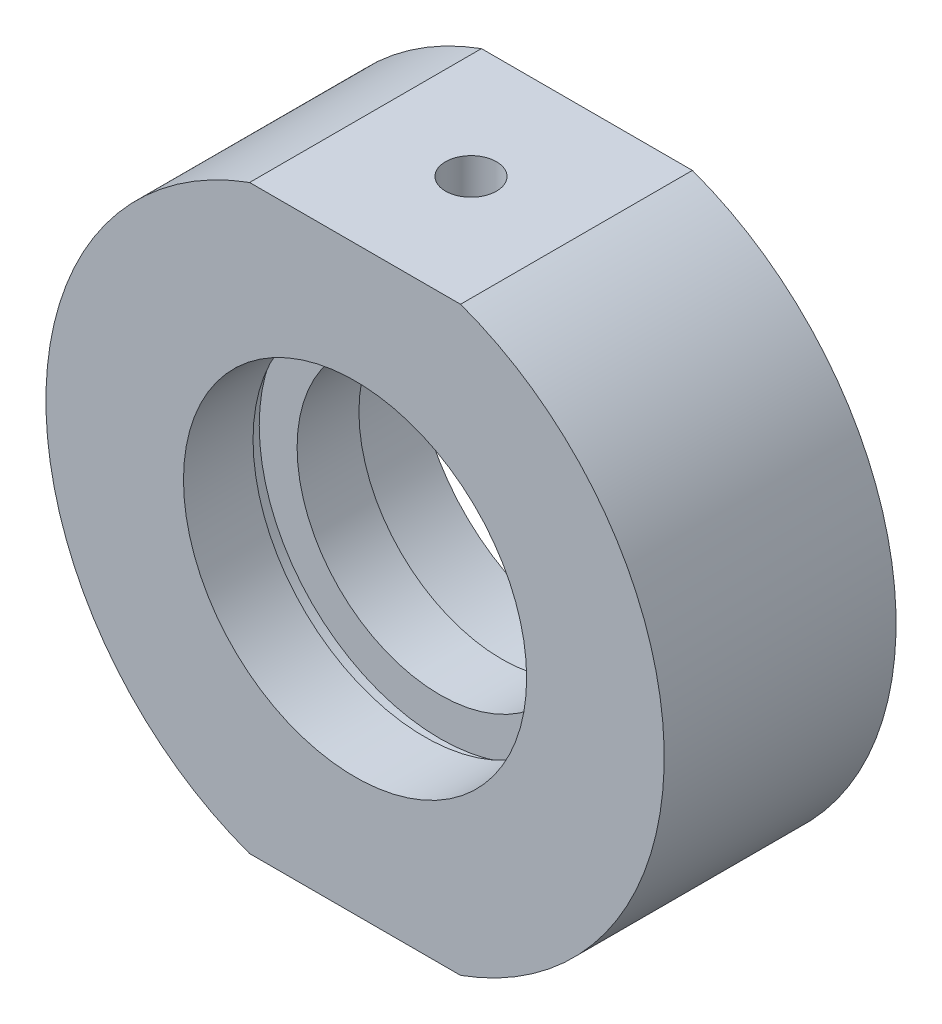
from build123d import *

# Parameters (mm, degrees)
SKETCH_2_W             = 64.02174429
SKETCH_2_H             = 9.248919907
CUT_EXTRUDE_1_DEPTH    = 49
HOLE_WIZARD_M4_2_D     = 3.3
HOLE_WIZARD_M4_2_DEPTH = 5.5
HOLE_WIZARD_M4_2_TIP   = 0.991420021
HOLE_WIZARD_M6_2_D     = 5
HOLE_WIZARD_M6_2_DEPTH = 5.5
HOLE_WIZARD_M6_2_TIP   = 1.502151548


with BuildPart() as part:
    # 草图1 → 旋转1 (revolve)
    with BuildSketch(Plane(origin=(0, 0, 0), x_dir=(1, 0, 0), z_dir=(0, 1, 0)), mode=Mode.PRIVATE) as revolve_1_sk:
        Polygon((20, 7.5), (20, -7.5), (11.1, -7.5), (11.1, -3), (11.7, -3), (11.7, -2), (9.25, -2), (9.25, 2), (11.7, 2), (11.7, 3), (11.1, 3), (11.1, 7.5), align=None)
    revolve(revolve_1_sk.sketch.rotate(Axis((0, 0, -31.9390681), (0, 0, 1)), 180), axis=Axis((0, 0, -31.9390681), (0, 0, 1)))  # turned: the seam where the file's is

    # 草图2 → 切除-拉伸1 (cut)
    with BuildSketch(Plane.XY.offset(7.5)):
        with Locations((-1.141100508, 23.424459954)):
            Rectangle(SKETCH_2_W, SKETCH_2_H)
        with Locations((-1.141100508, -23.424459954)):
            Rectangle(SKETCH_2_W, SKETCH_2_H)
    extrude(amount=-CUT_EXTRUDE_1_DEPTH, mode=Mode.SUBTRACT)

    # M4 螺纹孔2
    with Locations(Plane(origin=(0, 18.8, 0), x_dir=(1, 0, 0), z_dir=(0, 1, 0))):
        with Locations((0, 0)):
            Hole(HOLE_WIZARD_M4_2_D / 2, depth=HOLE_WIZARD_M4_2_DEPTH)
            with Locations((0, 0, -(HOLE_WIZARD_M4_2_DEPTH + HOLE_WIZARD_M4_2_TIP / 2))):  # 118° drill point
                Cone(0, HOLE_WIZARD_M4_2_D / 2, HOLE_WIZARD_M4_2_TIP, mode=Mode.SUBTRACT)

    # M6 螺纹孔2
    with Locations(Plane(origin=(0, -18.8, 0), x_dir=(-1, 0, 0), z_dir=(0, -1, 0))):
        with Locations((0, 0)):
            Hole(HOLE_WIZARD_M6_2_D / 2, depth=HOLE_WIZARD_M6_2_DEPTH)
            with Locations((0, 0, -(HOLE_WIZARD_M6_2_DEPTH + HOLE_WIZARD_M6_2_TIP / 2))):  # 118° drill point
                Cone(0, HOLE_WIZARD_M6_2_D / 2, HOLE_WIZARD_M6_2_TIP, mode=Mode.SUBTRACT)


solid = part.part
